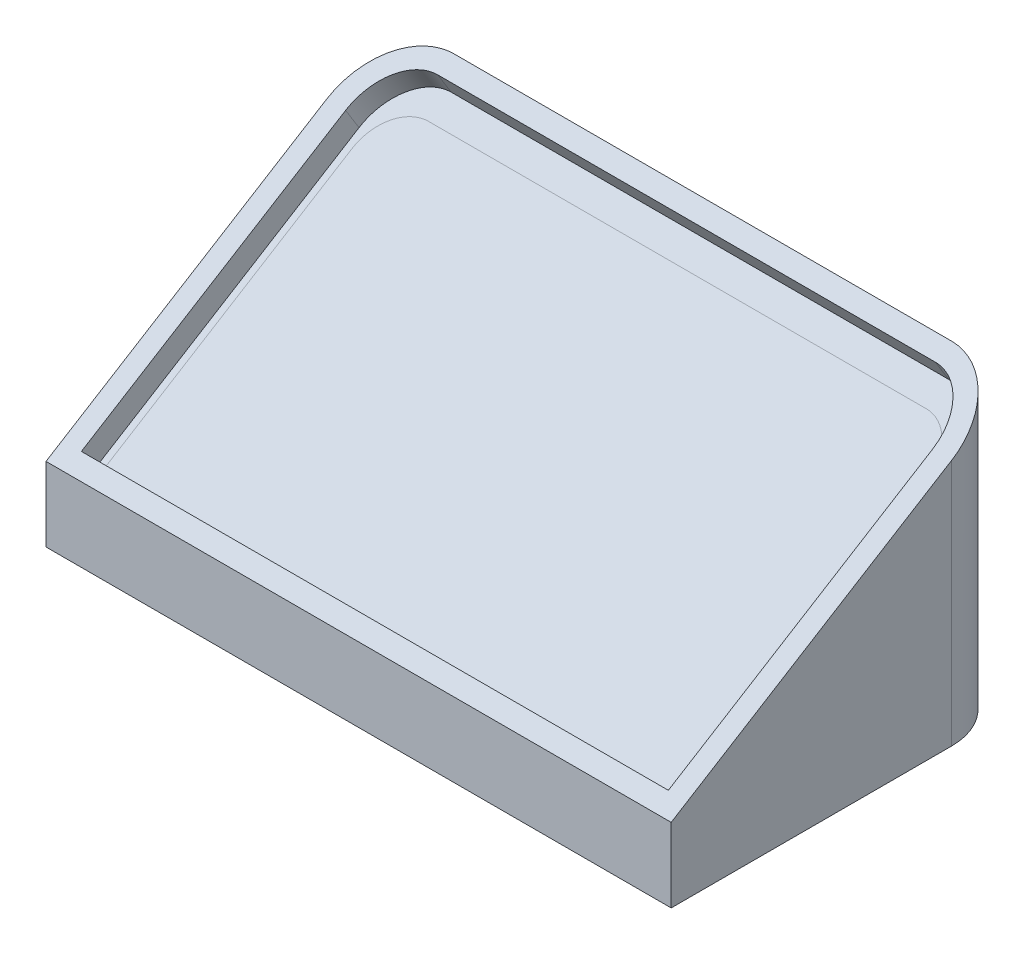
from build123d import *

# Parameters (mm, degrees)
SKETCH1_W           = 135
SKETCH1_H           = 30
BOSS_EXTRUDE1_DEPTH = 2.5
CUT_EXTRUDE1_DEPTH  = 3.5
BOSS_EXTRUDE2_DEPTH = 25
CUT_EXTRUDE2_DEPTH  = 3.5
CUT_EXTRUDE3_DEPTH  = 133
BOSS_EXTRUDE3_DEPTH = 2
SKETCH7_W           = 2
SKETCH7_H           = 5.815799519
BOSS_EXTRUDE4_DEPTH = 45.036412
CUT_EXTRUDE4_DEPTH  = 2
BOSS_EXTRUDE6_DEPTH = 2
BOSS_EXTRUDE8_REACH = 24.5
CUT_EXTRUDE5_DEPTH  = 10


with BuildPart() as part:
    # Sketch1 → Boss-Extrude1 (new body)
    with BuildSketch(Plane(origin=(0, 0, 0), x_dir=(1, 0, 0), z_dir=(0, 1, 0))):
        Rectangle(SKETCH1_W, SKETCH1_H)
    extrude(amount=BOSS_EXTRUDE1_DEPTH)

    # Sketch2 → Cut-Extrude1 (cut, through all)
    with BuildSketch(Plane(origin=(0, 2.5, 0), x_dir=(1, 0, 0), z_dir=(0, 1, 0))):
        Polygon((-67.5, 12), (0, 14.8), (67.5, 12), (67.5, 15), (-67.5, 15), align=None)
    extrude(amount=-CUT_EXTRUDE1_DEPTH, mode=Mode.SUBTRACT)

    # Sketch3 → Boss-Extrude2 (add)
    with BuildSketch(Plane(origin=(0, 2.5, 0), x_dir=(1, 0, 0), z_dir=(0, 1, 0))):
        with BuildLine():
            Line((62.5, -15), (62.5, 7))
            ThreePointArc((62.5, 7), (61.621320344, 9.121320344), (59.5, 10))
            Line((59.5, 10), (20.463588448, 10))
            ThreePointArc((20.463588448, 10), (18.342268104, 9.121320344), (17.463588448, 7))
            Line((17.463588448, 7), (17.463588448, -15))
            Line((17.463588448, -15), (15.463588448, -15))
            Line((15.463588448, -15), (15.463588448, 7))
            ThreePointArc((15.463588448, 7), (16.928054542, 10.535533906), (20.463588448, 12))
            Line((20.463588448, 12), (59.5, 12))
            ThreePointArc((59.5, 12), (63.035533906, 10.535533906), (64.5, 7))
            Line((64.5, 7), (64.5, -15))
            Line((64.5, -15), (62.5, -15))
        make_face()
    extrude(amount=BOSS_EXTRUDE2_DEPTH)

    # Sketch4 → Cut-Extrude2 (cut, through all)
    with BuildSketch(Plane(origin=(0, 2.5, 0), x_dir=(1, 0, 0), z_dir=(0, 1, 0))):
        with BuildLine():
            Line((62.5, -15), (62.5, 7))
            ThreePointArc((62.5, 7), (61.621320344, 9.121320344), (59.5, 10))
            Line((59.5, 10), (20.463588448, 10))
            ThreePointArc((20.463588448, 10), (18.342268104, 9.121320344), (17.463588448, 7))
            Line((17.463588448, 7), (17.463588448, -15))
            Line((17.463588448, -15), (62.5, -15))
        make_face()
    extrude(amount=-CUT_EXTRUDE2_DEPTH, mode=Mode.SUBTRACT)

    # Sketch5 → Cut-Extrude3 (cut, through all)
    with BuildSketch(Plane(origin=(64.5, 0, 0), x_dir=(0, 0, -1), z_dir=(1, 0, 0))):
        Polygon((-15, 5.815799519), (12, 22.5), (12, 27.5), (-15, 27.5), align=None)
    extrude(amount=-CUT_EXTRUDE3_DEPTH, mode=Mode.SUBTRACT)

    # Sketch6 → Boss-Extrude3 (add)
    with BuildSketch(Plane(origin=(0, 10.91644621, 6.745636189), x_dir=(1, 0, 0), z_dir=(0, 0.850689093, 0.525669162))):
        with BuildLine():
            Line((62.5, -9.703149931), (62.5, 16.158237255))
            add(Edge.make_bspline(
                [(62.5, 16.158237255), (62.5, 19.684790054), (59.5, 19.684790054)],
                knots=[1.570796327, 1.570796327, 1.570796327, 3.141592654, 3.141592654, 3.141592654], degree=2, weights=[1, 0.707106781, 1]))
            Line((59.5, 19.684790054), (20.463588448, 19.684790054))
            add(Edge.make_bspline(
                [(20.463588448, 19.684790054), (17.463588448, 19.684790054), (17.463588448, 16.158237255)],
                knots=[3.141592654, 3.141592654, 3.141592654, 4.71238898, 4.71238898, 4.71238898], degree=2, weights=[1, 0.707106781, 1]))
            Line((17.463588448, 16.158237255), (17.463588448, -9.703149931))
            Line((17.463588448, -9.703149931), (62.5, -9.703149931))
        make_face()
    extrude(amount=-BOSS_EXTRUDE3_DEPTH)

    # Sketch7 → Boss-Extrude4 (add)
    with BuildSketch(Plane(origin=(17.463588448, 0, 0), x_dir=(0, 0, -1), z_dir=(1, 0, 0))):
        with Locations((-14, 2.90789976)):
            Rectangle(SKETCH7_W, SKETCH7_H)
    extrude(amount=BOSS_EXTRUDE4_DEPTH)

    # Sketch8 → Cut-Extrude4 (cut)
    with BuildSketch(Plane(origin=(0, 10.91644621, 6.745636189), x_dir=(1, 0, 0), z_dir=(0, 0.850689093, 0.525669162))):
        with BuildLine():
            Line((16.963588448, -8.203149931), (63, -8.203149931))
            Line((63, -8.203149931), (63, 16.158237255))
            add(Edge.make_bspline(
                [(63, 16.158237255), (63, 16.678430051), (62.927246406, 17.184916133), (62.706402595, 17.923598547), (62.612586146, 18.168278902), (62.388791314, 18.633558431), (62.258852125, 18.855435186), (61.959006889, 19.275346047), (61.787397581, 19.474525186), (61.412050459, 19.828509286), (61.207271339, 19.985519424), (60.75725336, 20.25137755), (60.520800183, 20.354971762), (60.022800139, 20.497837607), (59.761760868, 20.535825252), (59.5, 20.535825252)],
                knots=[0, 0, 0, 0, 0.25, 0.25, 0.375, 0.375, 0.5, 0.5, 0.625, 0.625, 0.75, 0.75, 0.875, 0.875, 1, 1, 1, 1], degree=3))
            Line((59.5, 20.535825252), (20.463588448, 20.535825252))
            add(Edge.make_bspline(
                [(20.463588448, 20.535825252), (20.202590256, 20.535825252), (19.94808239, 20.499165485), (19.575317783, 20.393356351), (19.451909017, 20.349157798), (19.214372721, 20.246481447), (19.099575132, 20.187913614), (18.766217208, 19.992117688), (18.557246112, 19.833184369), (18.181207194, 19.479944242), (18.011381469, 19.283867426), (17.708851233, 18.862163664), (17.578392986, 18.640035937), (17.35419362, 18.175882409), (17.260169716, 17.932109778), (17.111675708, 17.438316882), (17.05647927, 17.187351348), (16.982384638, 16.677667191), (16.963588448, 16.417938824), (16.963588448, 16.158237255)],
                knots=[0, 0, 0, 0, 0.125, 0.125, 0.1875, 0.1875, 0.25, 0.25, 0.375, 0.375, 0.5, 0.5, 0.625, 0.625, 0.75, 0.75, 0.875, 0.875, 1, 1, 1, 1], degree=3))
            Line((16.963588448, 16.158237255), (16.963588448, -8.203149931))
        make_face()
    extrude(amount=-CUT_EXTRUDE4_DEPTH, mode=Mode.SUBTRACT)

    # Sketch13 → Cut-Extrude5 (cut)
    with BuildSketch(Plane(origin=(0, 2.5, 0), x_dir=(1, 0, 0), z_dir=(0, 1, 0))):
        with BuildLine():
            Line((15.463588448, -15), (15.463588448, 7))
            ThreePointArc((15.463588448, 7), (16.928054542, 10.535533906), (20.463588448, 12))
            Line((20.463588448, 12), (59.5, 12))
            ThreePointArc((59.5, 12), (63.035533906, 10.535533906), (64.5, 7))
            Line((64.5, 7), (64.5, -15))
            Line((64.5, -15), (67.5, -15))
            Line((67.5, -15), (67.5, 12))
            Line((67.5, 12), (0, 14.8))
            Line((0, 14.8), (-67.5, 12))
            Line((-67.5, 12), (-67.5, -15))
            Line((-67.5, -15), (15.463588448, -15))
        make_face()
    extrude(amount=-CUT_EXTRUDE5_DEPTH, mode=Mode.SUBTRACT)


with BuildPart() as body_2:
    # Sketch10 → Boss-Extrude6 (new body)
    with BuildSketch(Plane(origin=(0, 9.215068025, 5.694297866), x_dir=(1, 0, 0), z_dir=(0, 0.850689093, 0.525669162))):
        with BuildLine():
            Line((20.463588448, 18.448923351), (59.5, 18.448923351))
            add(Edge.make_bspline(
                [(62.5, 14.922370553), (62.5, 18.448923351), (59.5, 18.448923351)],
                knots=[1.570796327, 1.570796327, 1.570796327, 3.141592654, 3.141592654, 3.141592654], degree=2, weights=[1, 0.707106781, 1]))
            Line((62.5, 14.922370553), (62.5, -8.203149931))
            Line((62.5, -8.203149931), (17.463588448, -8.203149931))
            Line((17.463588448, -8.203149931), (17.463588448, 14.922370553))
            add(Edge.make_bspline(
                [(20.463588448, 18.448923351), (17.463588448, 18.448923351), (17.463588448, 14.922370553)],
                knots=[3.141592654, 3.141592654, 3.141592654, 4.71238898, 4.71238898, 4.71238898], degree=2, weights=[1, 0.707106781, 1]))
        make_face()
    extrude(amount=-BOSS_EXTRUDE6_DEPTH)


with BuildPart() as body_3:

    # Boss-Extrude8: up to this face of the body (flat: up to its plane)
    boss_extrude8_end = Plane(body_2.part.faces().sort_by_distance((39.981794224, 10.18160471, 0.325479564))[0])
    # Sketch12 → Boss-Extrude8 (new body, up to the picked face)
    with BuildSketch(Plane.XZ, mode=Mode.PRIVATE) as boss_extrude8_sk1:
        with BuildLine():
            Line((62.5, 13), (17.463588448, 13))
            Line((17.463588448, 13), (17.463588448, -7))
            ThreePointArc((17.463588448, -7), (18.342268104, -9.121320344), (20.463588448, -10))
            Line((20.463588448, -10), (59.5, -10))
            ThreePointArc((59.5, -10), (61.621320344, -9.121320344), (62.5, -7))
            Line((62.5, -7), (62.5, 13))
        make_face()
    boss_extrude8_tool1 = split(extrude(boss_extrude8_sk1.sketch, amount=-BOSS_EXTRUDE8_REACH, mode=Mode.PRIVATE), bisect_by=boss_extrude8_end, keep=Keep.BOTH, mode=Mode.PRIVATE)
    add(boss_extrude8_tool1.solids().sort_by_distance((39.981794, 0, 1.540538))[0])


solid = Compound([part.part, body_2.part, body_3.part])
